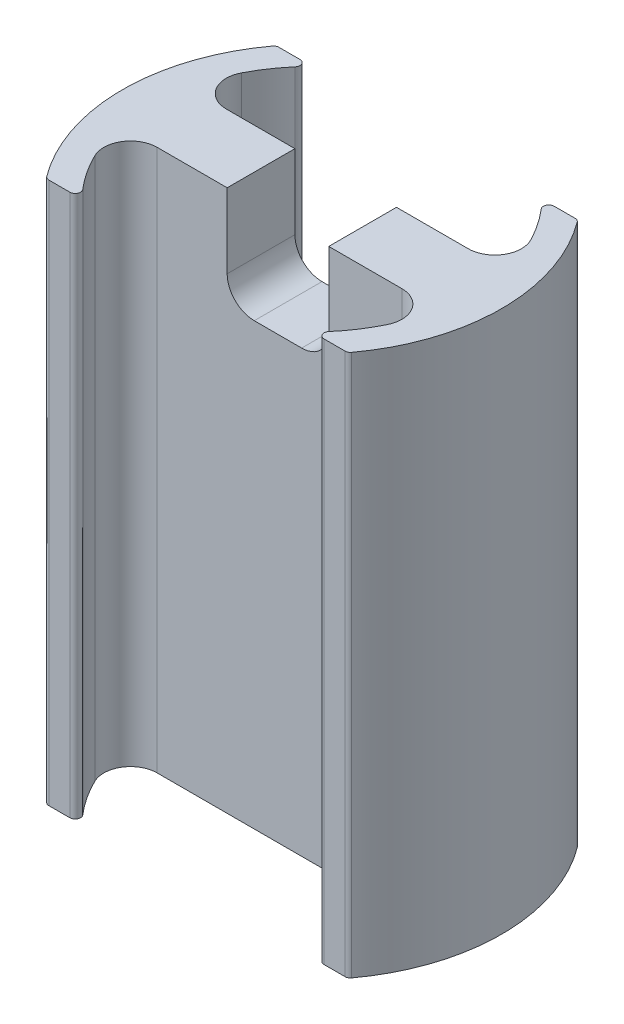
from build123d import *

# Parameters (mm, degrees)
BOSS_EXTRUDE2_DEPTH = 101.6
FILLET3_R           = 1
FILLET5_R           = 5
SKETCH8_R           = 3.175
CUT_EXTRUDE3_DEPTH  = 19.05
SKETCH9_W           = 19.05
SKETCH9_H           = 19.05
CUT_EXTRUDE4_DEPTH  = 12.7
FILLET6_R           = 5.08
SKETCH11_W          = 8
SKETCH11_H          = 12
CUT_EXTRUDE5_DEPTH  = 12.7
FILLET7_R           = 2.54


with BuildPart() as part:
    # Sketch2 → Boss-Extrude2 (new body)
    with BuildSketch(Plane(origin=(0, 0, 0), x_dir=(1, 0, 0), z_dir=(0, 1, 0))):
        with BuildLine():
            Line((-21.540573528, -21.56464913), (-28.275068663, -21.56464913))
            ThreePointArc((-28.275068663, -21.56464913), (-35.56, 0), (-28.275068663, 21.56464913))
            Line((-28.275068663, 21.56464913), (-21.540573528, 21.56464913))
            ThreePointArc((-21.540573528, 21.56464913), (-26.716830431, 14.671106698), (-29.7559672, 6.604))
            Line((-29.7559672, 6.604), (29.7559672, 6.604))
            ThreePointArc((29.7559672, 6.604), (26.716830431, 14.671106698), (21.540573528, 21.56464913))
            Line((21.540573528, 21.56464913), (28.275068663, 21.56464913))
            ThreePointArc((28.275068663, 21.56464913), (35.56, 0), (28.275068663, -21.56464913))
            Line((28.275068663, -21.56464913), (21.540573528, -21.56464913))
            ThreePointArc((21.540573528, -21.56464913), (26.840862889, -14.442938737), (29.864178944, -6.096))
            Line((29.864178944, -6.096), (-29.864178944, -6.096))
            ThreePointArc((-29.864178944, -6.096), (-26.840862889, -14.442938737), (-21.540573528, -21.56464913))
        make_face()
    extrude(amount=BOSS_EXTRUDE2_DEPTH)

    # Fillet3
    fillet3_edges = [part.edges().sort_by_distance(p)[0] for p in [
        (21.540573528, 50.8, -21.56464913),
        (28.275068663, 50.8, -21.56464913),
        (28.275068663, 50.8, 21.56464913),
        (21.540573528, 50.8, 21.56464913),
        (-21.540573528, 50.8, 21.56464913),
        (-28.275068663, 50.8, 21.56464913),
        (-28.275068663, 50.8, -21.56464913),
        (-21.540573528, 50.8, -21.56464913),
    ]]
    fillet(fillet3_edges, radius=FILLET3_R)

    # Fillet5
    fillet5_edges = [part.edges().sort_by_distance(p)[0] for p in [
        (29.864178944, 50.8, 6.096),
        (-29.864178944, 50.8, 6.096),
        (-29.7559672, 50.8, -6.604),
        (29.7559672, 50.8, -6.604),
    ]]
    fillet(fillet5_edges, radius=FILLET5_R)

    # Sketch8 → Cut-Extrude3 (cut)
    with BuildSketch(Plane(origin=(0, 101.6, 0), x_dir=(1, 0, 0), z_dir=(0, 1, 0))):
        Circle(SKETCH8_R)
    extrude(amount=-CUT_EXTRUDE3_DEPTH, mode=Mode.SUBTRACT)

    # Sketch9 → Cut-Extrude4 (cut)
    with BuildSketch(Plane.XY.offset(6.096)):
        with Locations((-0.285711728, 92.075)):
            Rectangle(SKETCH9_W, SKETCH9_H)
    extrude(amount=-CUT_EXTRUDE4_DEPTH, mode=Mode.SUBTRACT)

    # Fillet6
    fillet6_edges = [part.edges().sort_by_distance(p)[0] for p in [
        (9.239288272, 82.55, -0.254),
        (-9.810711728, 82.55, -0.254),
    ]]
    fillet(fillet6_edges, radius=FILLET6_R)

    # Sketch11 → Cut-Extrude5 (cut)
    with BuildSketch(Plane.XY.offset(6.096)):
        with Locations((12.587070083, 0)):
            Rectangle(SKETCH11_W, SKETCH11_H)
    extrude(amount=-CUT_EXTRUDE5_DEPTH, mode=Mode.SUBTRACT)

    # Fillet7
    fillet7_edges = [part.edges().sort_by_distance(p)[0] for p in [
        (16.587070083, 6, -0.254),
        (8.587070083, 6, -0.254),
    ]]
    fillet(fillet7_edges, radius=FILLET7_R)


solid = part.part
